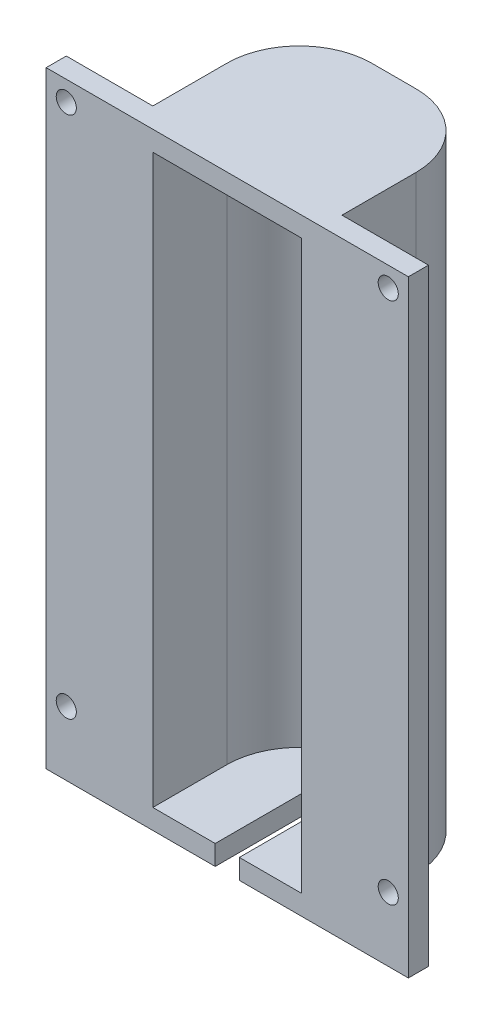
from build123d import *

# Parameters (mm, degrees)
BOSS_EXTRUDE1_DEPTH               = 18.2
SKETCH1_3_W                       = 45
SKETCH1_3_H                       = 75.45
BOSS_EXTRUDE2_DEPTH               = 5.5
FILLET1_R                         = 9
CUT_EXTRUDE1_DEPTH                = 103
TAP_DRILL_FOR_M3_TAP1_D           = 2.5
TAP_DRILL_FOR_M3_TAP1_CSINK_D     = 2.55
TAP_DRILL_FOR_M3_TAP1_CSINK_ANGLE = 90
FILLET2_R                         = 9


with BuildPart() as part:
    # Sketch1 → Boss-Extrude1 (new body)
    with BuildSketch(Plane.XY):
        Polygon((1.5, -37.725), (22.5, -37.725), (22.5, 37.725), (-22.5, 37.725), (-22.5, -37.725), (-1.5, -37.725), (-1.5, -35.25), (-9.25, -35.25), (-9.25, 35.25), (9.25, 35.25), (9.25, -35.25), (1.5, -35.25), align=None)
    extrude(amount=BOSS_EXTRUDE1_DEPTH)

    # Sketch1_3 → Boss-Extrude2 (add)
    with BuildSketch(Plane.XY):
        Rectangle(SKETCH1_3_W, SKETCH1_3_H)
    extrude(amount=-BOSS_EXTRUDE2_DEPTH)

    # Fillet1
    fillet1_edges = [part.edges().sort_by_distance(p)[0] for p in [
        (-9.25, 0, 0),
        (9.25, 0, 0),
    ]]
    fillet(fillet1_edges, radius=FILLET1_R)

    # Sketch4 → Cut-Extrude1 (cut)
    with BuildSketch(Plane.XZ.offset(37.725)):
        Polygon((-11.75, 15.7), (-22.5, 15.7), (-22.5, -5.5), (22.5, -5.5), (22.5, 15.7), (11.75, 15.7), (11.75, -2.5), (-11.75, -2.5), align=None)
    extrude(amount=-CUT_EXTRUDE1_DEPTH, mode=Mode.SUBTRACT)

    # Tap Drill for M3 Tap1 (through all)
    with Locations(Plane(origin=(0, 0, -5.5), x_dir=(-1, 0, 0), z_dir=(0, 0, -1))):
        with Locations((19.999953282, 35.25), (-20.000046718, 35.25), (-20.000046718, -29.75), (19.999953282, -29.75)):
            CounterSinkHole(TAP_DRILL_FOR_M3_TAP1_D / 2, TAP_DRILL_FOR_M3_TAP1_CSINK_D / 2, counter_sink_angle=TAP_DRILL_FOR_M3_TAP1_CSINK_ANGLE)

    # Fillet2
    fillet2_edges = [part.edges().sort_by_distance(p)[0] for p in [
        (-11.75, 0, -2.5),
        (11.75, 0, -2.5),
    ]]
    fillet(fillet2_edges, radius=FILLET2_R)


solid = part.part
